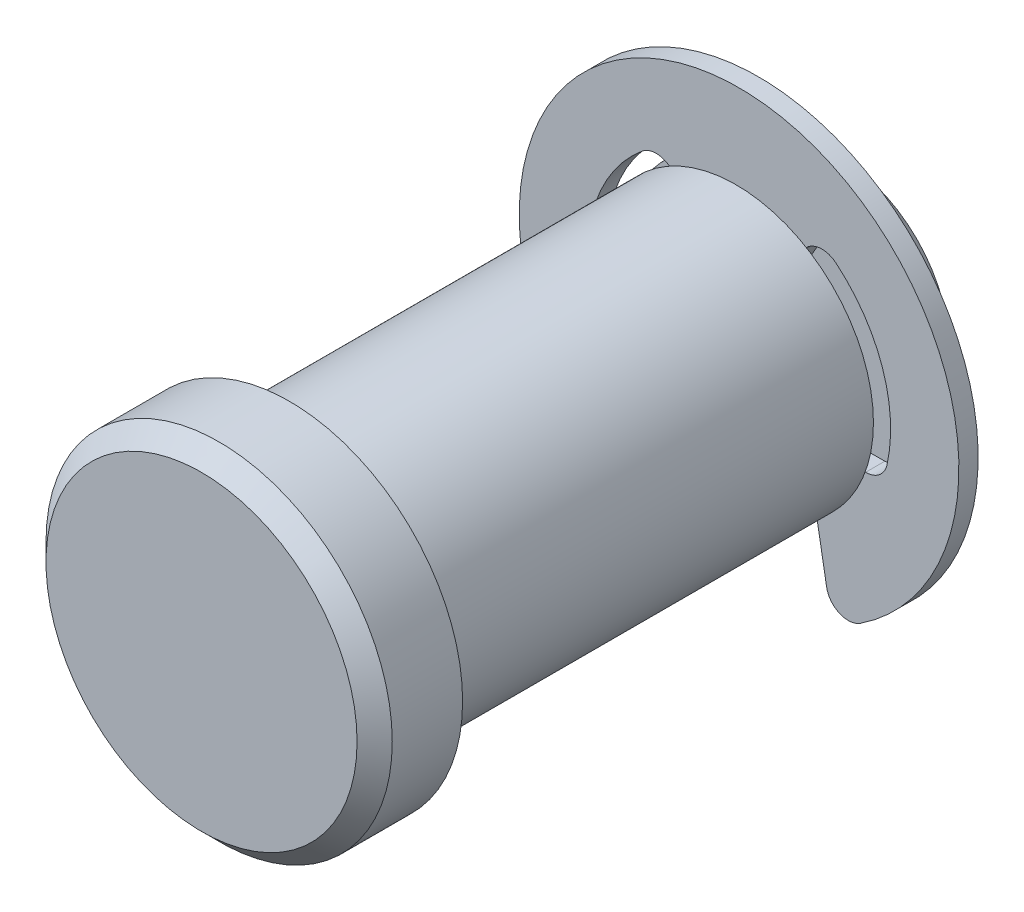
from build123d import *

# Parameters (mm, degrees)
SKETCH2_R      = 6.35
EXTRUDE1_DEPTH = 12.7
SKETCH3_W      = 1.1684
SKETCH3_H      = 2.5019
SKETCH8_R      = 8.001
EXTRUDE6_DEPTH = 4.064
CHAMFER2_SIZE  = 0.8128
SKETCH4_R      = 10.16
SKETCH4_R_2    = 3.8481
EXTRUDE2_DEPTH = 0.4445
EXTRUDE4_DEPTH = 13.7
EXTRUDE5_DEPTH = 0.889
FILLET1_R      = 1.016
CHAMFER1_SIZE  = 1.27


with BuildPart() as part:
    # Sketch2 → Extrude1 (new body, symmetric)
    with BuildSketch(Plane.XY):
        Circle(SKETCH2_R)
    extrude(amount=EXTRUDE1_DEPTH, both=True)

    # Sketch3 → Cut-Revolve1 (revolve, cut)
    with BuildSketch(Plane(origin=(0, 0, 0), x_dir=(0, 0, -1), z_dir=(1, 0, 0))):
        with Locations((8.5217, 5.09905)):
            Rectangle(SKETCH3_W, SKETCH3_H)
    revolve(axis=Axis((0, 0, 12.7), (0, 0, -1)), mode=Mode.SUBTRACT)

    # Sketch8 → Extrude6 (add)
    with BuildSketch(Plane.XY.offset(12.7)):
        Circle(SKETCH8_R)
    extrude(amount=EXTRUDE6_DEPTH)

    # Chamfer2
    chamfer2_edges = [part.edges().sort_by_distance(p)[0] for p in [
        (-8.001, 0, 16.764),
    ]]
    chamfer(chamfer2_edges, length=CHAMFER2_SIZE)

    # Chamfer1
    chamfer1_edges = [part.edges().sort_by_distance(p)[0] for p in [
        (-6.35, 0, -12.7),
    ]]
    chamfer(chamfer1_edges, length=CHAMFER1_SIZE)


with BuildPart() as body_2:
    # Sketch4 → Extrude2 (new body, symmetric)
    with BuildSketch(Plane.XY.offset(-8.5217)):
        Circle(SKETCH4_R)
        Circle(SKETCH4_R_2, mode=Mode.SUBTRACT)
    extrude(amount=EXTRUDE2_DEPTH, both=True)

    # Sketch5 → Extrude4 (cut, through all)
    with BuildSketch(Plane.XY):
        with BuildLine():
            Line((-3.502025, 6.065685229), (0, 0))
            Line((0, 0), (3.502025, 6.065685229))
            ThreePointArc((3.502025, 6.065685229), (6.565777443, 2.438705183), (6.61255487, -2.30886))
            Line((6.61255487, -2.30886), (3.07848, -2.30886))
            Line((3.07848, -2.30886), (4.294908828, -9.207570698))
            ThreePointArc((4.294908828, -9.207570698), (0, -10.16), (-4.294908828, -9.207570698))
            Line((-4.294908828, -9.207570698), (-3.07848, -2.30886))
            Line((-3.07848, -2.30886), (-6.61255487, -2.30886))
            ThreePointArc((-6.61255487, -2.30886), (-6.565777443, 2.438705183), (-3.502025, 6.065685229))
        make_face()
    extrude(amount=-EXTRUDE4_DEPTH, mode=Mode.SUBTRACT)

    # Sketch6 → Extrude5 (add)
    with BuildSketch(Plane.XY.offset(-8.0772)):
        with BuildLine():
            Line((-1.92405, 3.332552356), (1.92405, 3.332552356))
            ThreePointArc((1.92405, 3.332552356), (0, 3.8481), (-1.92405, 3.332552356))
        make_face()
    extrude(amount=-EXTRUDE5_DEPTH)

    # Fillet1
    fillet1_edges = [body_2.edges().sort_by_distance(p)[0] for p in [
        (3.502025, 6.065685229, -8.5217),
        (4.294908828, -9.207570698, -8.5217),
        (-6.61255487, -2.30886, -8.5217),
        (6.61255487, -2.30886, -8.5217),
        (-4.294908828, -9.207570698, -8.5217),
        (-3.502025, 6.065685229, -8.5217),
    ]]
    fillet(fillet1_edges, radius=FILLET1_R)


solid = Compound([part.part, body_2.part])
